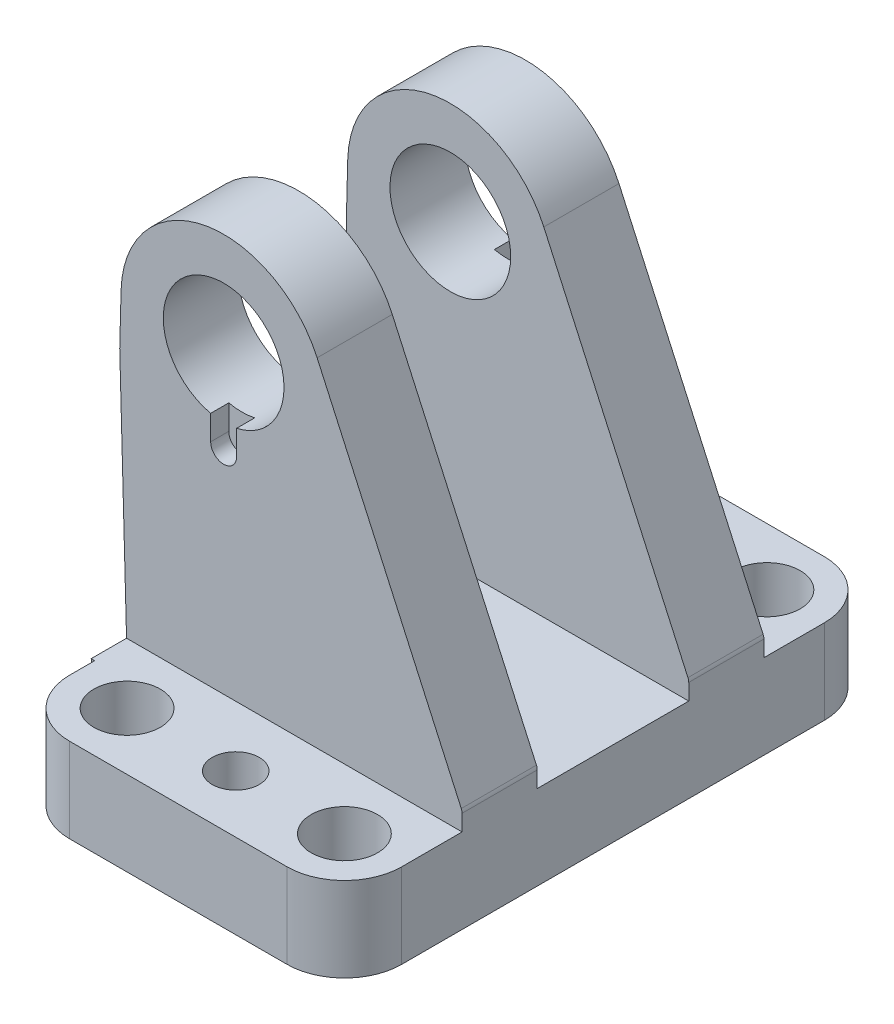
from build123d import *

# Parameters (mm, degrees)
SKETCH1_R                = 5.5
SKETCH1_R_2              = 3.9
BOSS_EXTRUDE1_DEPTH      = 14
BOSS_EXTRUDE2_DEPTH      = 30.85
BOSS_EXTRUDE2_DEPTH_BACK = 30.85
SKETCH3_R                = 10
BOSS_EXTRUDE3_DEPTH      = 12.45
SKETCH4_R                = 10
BOSS_EXTRUDE4_DEPTH      = 12.45
CUT_EXTRUDE1_DEPTH       = 3
CUT_EXTRUDE1_DEPTH_BACK  = 3
CUT_EXTRUDE2_DEPTH       = 3
CUT_EXTRUDE2_DEPTH_BACK  = 3


with BuildPart() as part:
    # Sketch1 → Boss-Extrude1 (new body)
    with BuildSketch(Plane(origin=(0, 0, 0), x_dir=(1, 0, 0), z_dir=(0, 1, 0))):
        with BuildLine():
            Line((-18, -44.5), (18, -44.5))
            ThreePointArc((18, -44.5), (24.717514421, -41.717514421), (27.5, -35))
            Line((27.5, -35), (27.5, 35))
            ThreePointArc((27.5, 35), (24.717514421, 41.717514421), (18, 44.5))
            Line((18, 44.5), (-18, 44.5))
            ThreePointArc((-18, 44.5), (-24.717514421, 41.717514421), (-27.5, 35))
            Line((-27.5, 35), (-27.5, -35))
            ThreePointArc((-27.5, -35), (-24.717514421, -41.717514421), (-18, -44.5))
        make_face()
        with Locations((18, 35)):
            Circle(SKETCH1_R, mode=Mode.SUBTRACT)
        with Locations((18, -35)):
            Circle(SKETCH1_R, mode=Mode.SUBTRACT)
        with Locations((0, 35)):
            Circle(SKETCH1_R_2, mode=Mode.SUBTRACT)
        with Locations((0, -35)):
            Circle(SKETCH1_R_2, mode=Mode.SUBTRACT)
        with Locations((-18, 35)):
            Circle(SKETCH1_R, mode=Mode.SUBTRACT)
        with Locations((-18, -35)):
            Circle(SKETCH1_R, mode=Mode.SUBTRACT)
    extrude(amount=BOSS_EXTRUDE1_DEPTH)

    # Sketch2 → Boss-Extrude2 (add, two sides)
    with BuildSketch(Plane.XY) as boss_extrude2_sk:
        Polygon((-28.085675658, 14), (-27.7, 0), (-22.7, 0), (-22.7, 14), align=None)
    extrude(amount=BOSS_EXTRUDE2_DEPTH)
    extrude(boss_extrude2_sk.sketch, amount=-BOSS_EXTRUDE2_DEPTH_BACK)

    # Sketch3 → Boss-Extrude3 (add)
    with BuildSketch(Plane.XY.offset(25)):
        with BuildLine():
            Line((-29.215236642, 55.002986453), (-27.7, 0))
            Line((-27.7, 0), (27.5, 0))
            Line((27.5, 0), (27.5, 16.676103914))
            ThreePointArc((27.5, 16.676103914), (27.466207658, 16.992703195), (27.366353194, 17.295037634))
            Line((27.366353194, 17.295037634), (3.485336194, 70.014582166))
            ThreePointArc((3.485336194, 70.014582166), (-15.37030771, 79.662563606), (-28.994174525, 63.445008121))
            Line((-28.994174525, 63.445008121), (-29.215236642, 55.002986453))
        make_face()
        with Locations((-12, 63)):
            Circle(SKETCH3_R, mode=Mode.SUBTRACT)
    extrude(amount=-BOSS_EXTRUDE3_DEPTH)

    # Sketch4 → Boss-Extrude4 (add)
    with BuildSketch(Plane.XY.offset(-25)):
        with BuildLine():
            Line((-29.215236642, 55.002986453), (-27.7, 0))
            Line((-27.7, 0), (27.5, 0))
            Line((27.5, 0), (27.5, 16.676103914))
            ThreePointArc((27.5, 16.676103914), (27.466207658, 16.992703195), (27.366353194, 17.295037634))
            Line((27.366353194, 17.295037634), (3.485336194, 70.014582166))
            ThreePointArc((3.485336194, 70.014582166), (-15.37030771, 79.662563606), (-28.994174525, 63.445008121))
            Line((-28.994174525, 63.445008121), (-29.215236642, 55.002986453))
        make_face()
        with Locations((-12, 63)):
            Circle(SKETCH4_R, mode=Mode.SUBTRACT)
    extrude(amount=BOSS_EXTRUDE4_DEPTH)

    # Sketch5 → Cut-Extrude1 (cut, two sides)
    with BuildSketch(Plane.XY.offset(25)) as cut_extrude1_sk:
        with BuildLine():
            Line((-9.85, 49.15), (-9.85, 63))
            Line((-9.85, 63), (-14.15, 63))
            Line((-14.15, 63), (-14.15, 49.15))
            ThreePointArc((-14.15, 49.15), (-12, 47), (-9.85, 49.15))
        make_face()
    extrude(amount=CUT_EXTRUDE1_DEPTH, mode=Mode.SUBTRACT)
    extrude(cut_extrude1_sk.sketch, amount=-CUT_EXTRUDE1_DEPTH_BACK, mode=Mode.SUBTRACT)

    # Sketch6 → Cut-Extrude2 (cut, two sides)
    with BuildSketch(Plane.XY.offset(-25)) as cut_extrude2_sk:
        with BuildLine():
            Line((-9.85, 49.15), (-9.85, 63))
            Line((-9.85, 63), (-14.15, 63))
            Line((-14.15, 63), (-14.15, 49.15))
            ThreePointArc((-14.15, 49.15), (-12, 47), (-9.85, 49.15))
        make_face()
    extrude(amount=CUT_EXTRUDE2_DEPTH, mode=Mode.SUBTRACT)
    extrude(cut_extrude2_sk.sketch, amount=-CUT_EXTRUDE2_DEPTH_BACK, mode=Mode.SUBTRACT)


solid = part.part
